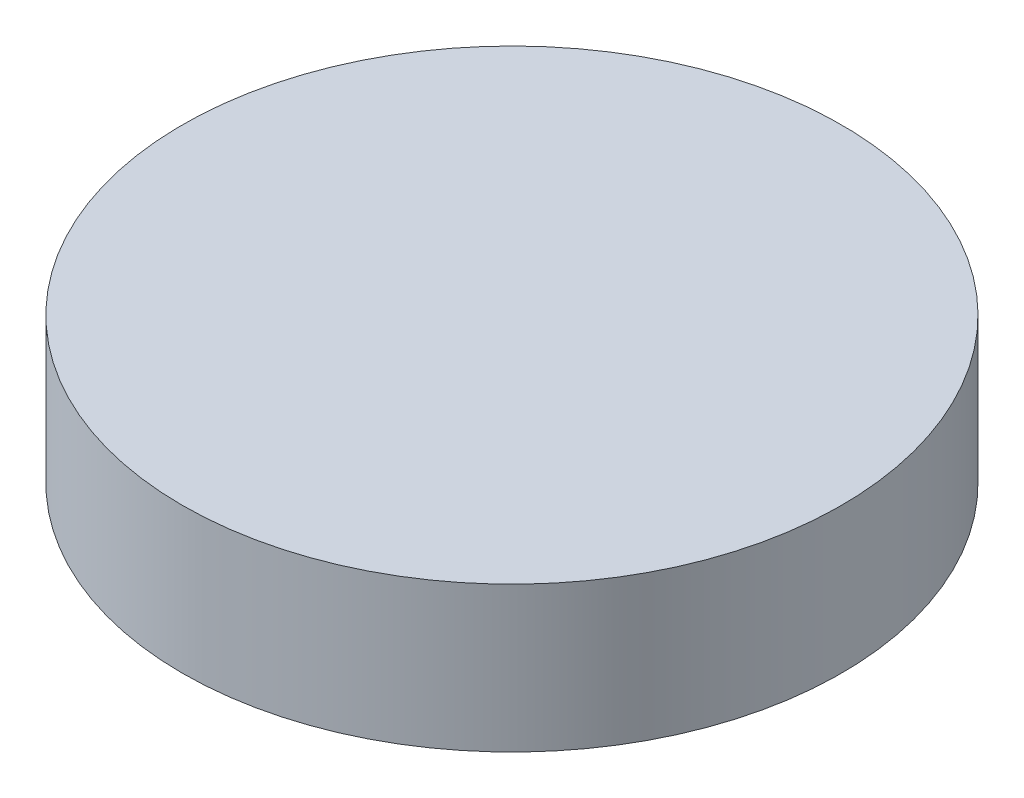
from build123d import *

# Parameters (mm, degrees)
SKETCH1_R           = 34
BOSS_EXTRUDE2_DEPTH = 15
SKETCH4_R           = 3
CUT_EXTRUDE1_DEPTH  = 10


with BuildPart() as part:
    # Sketch1 → Boss-Extrude2 (new body)
    with BuildSketch(Plane(origin=(0, 0, 0), x_dir=(1, 0, 0), z_dir=(0, 1, 0))):
        Circle(SKETCH1_R)
    extrude(amount=BOSS_EXTRUDE2_DEPTH)

    # Sketch4 → Cut-Extrude1 (cut)
    with BuildSketch(Plane.XZ):
        with Locations((12, 0)):
            Circle(SKETCH4_R)
    extrude(amount=-CUT_EXTRUDE1_DEPTH, mode=Mode.SUBTRACT)


solid = part.part
